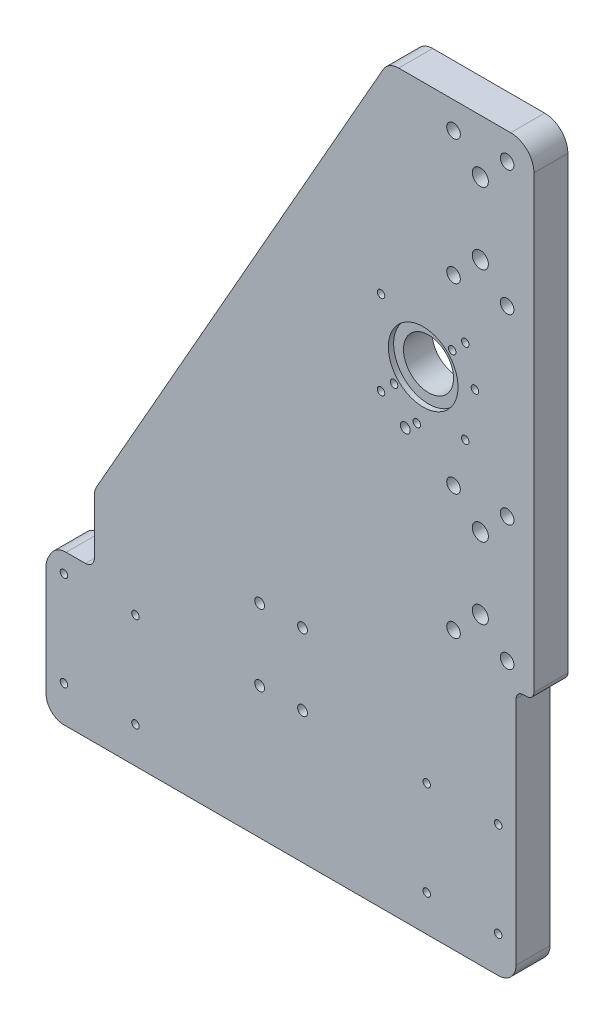
from build123d import *

# Parameters (mm, degrees)
SKETCH2_W               = 270.829085825
SKETCH2_H               = 402
BOSS_EXTRUDE1_DEPTH     = 19
SKETCH3_W               = 7.829085824
SKETCH3_H               = 419.560715459
CUT_EXTRUDE1_DEPTH      = 20
CUT_EXTRUDE2_DEPTH      = 20
FILLET1_R               = 10
TAP_DRILL_FOR_M5_TAP1_D = 4.2
FILLET2_R               = 3
M7_CLEARANCE_HOLE1_D    = 7.6
SKETCH11_R              = 19.5
CUT_EXTRUDE4_DEPTH      = 32.266788686
CUT_EXTRUDE5_DEPTH      = 20
FILLET3_R               = 10
FILLET4_R               = 5
TAP_DRILL_FOR_M5_TAP2_D = 4.2
BOSS_EXTRUDE2_DEPTH     = 19
SKETCH16_R              = 19.5
SKETCH16_R_2            = 14
BOSS_EXTRUDE3_DEPTH     = 16
M5_CLEARANCE_HOLE4_D    = 5.5
M5_CLEARANCE_HOLE5_D    = 5.5
M8_CLEARANCE_HOLE1_D    = 9
TAP_DRILL_FOR_M5_TAP3_D = 4.2
CUT_EXTRUDE6_DEPTH      = 4


with BuildPart() as part:
    # Sketch2 → Boss-Extrude1 (new body)
    with BuildSketch(Plane.XY.offset(94)):
        with Locations((2322.392578952, 658.909518743)):
            Rectangle(SKETCH2_W, SKETCH2_H)
    extrude(amount=BOSS_EXTRUDE1_DEPTH)

    # Sketch3 → Cut-Extrude1 (cut)
    with BuildSketch(Plane.XY.offset(113)):
        with Locations((2190.892578951, 654.789569031)):
            Rectangle(SKETCH3_W, SKETCH3_H)
    extrude(amount=-CUT_EXTRUDE1_DEPTH, mode=Mode.SUBTRACT)

    # Sketch4 → Cut-Extrude2 (cut)
    with BuildSketch(Plane.XY.offset(113)):
        Polygon((2194.807121863, 532.656963015), (2380.609228318, 859.909518743), (2194.807121863, 859.909518743), align=None)
    extrude(amount=-CUT_EXTRUDE2_DEPTH, mode=Mode.SUBTRACT)

    # Fillet1
    fillet1_edges = [part.edges().sort_by_distance(p)[0] for p in [
        (2194.807121863, 457.909518743, 103.5),
        (2194.807121863, 532.656963015, 103.5),
        (2380.609228318, 859.909518743, 103.5),
        (2457.807121864, 457.909518743, 103.5),
    ]]
    fillet(fillet1_edges, radius=FILLET1_R)

    # Tap Drill for M5 Tap1 (through all)
    with Locations(Plane.XY.offset(113)):
        with Locations((2338.307121864, 531.660659234), (2314.307121864, 531.660659234), (2314.307121864, 571.660659234), (2338.307121864, 571.660659234), (2447.807121864, 531.160659234), (2447.807121864, 478.160659234), (2407.807121864, 478.160659234), (2407.807121864, 531.160659234), (2244.807121863, 531.160659234), (2244.807121863, 478.160659234), (2204.807121863, 478.160659234), (2204.807121863, 531.160659234)):
            Hole(TAP_DRILL_FOR_M5_TAP1_D / 2)

    # Fillet2
    fillet2_edges = [part.edges().sort_by_distance(p)[0] for p in [
        (2457.807121864, 859.909518743, 103.5),
    ]]
    fillet(fillet2_edges, radius=FILLET2_R)

    # M7 Clearance Hole1 (through all)
    with Locations(Plane.XY.offset(113)):
        with Locations((2422.807121864, 612.909518743), (2437.807121864, 627.909518743), (2452.807121864, 612.909518743), (2452.807121864, 682.909518743), (2437.807121864, 667.909518743), (2422.807121864, 682.909518743), (2452.807121864, 784.909518743), (2422.807121864, 854.909518743), (2452.807121864, 854.909518743), (2422.807121864, 784.909518743), (2437.807121864, 799.909518743), (2437.807121864, 839.909518743)):
            Hole(M7_CLEARANCE_HOLE1_D / 2)

    # Sketch11 → Cut-Extrude4 (cut)
    with BuildSketch(Plane.XY.offset(113)):
        with Locations((2405.807121866, 731.909518744)):
            Circle(SKETCH11_R)
    extrude(amount=-CUT_EXTRUDE4_DEPTH, mode=Mode.SUBTRACT)

    # Sketch12 → Cut-Extrude5 (cut)
    with BuildSketch(Plane.XY.offset(113)):
        Polygon((2221.807121863, 542.160659234), (2189.780449764, 542.160659234), (2221.807121863, 583.425794439), align=None)
    extrude(amount=-CUT_EXTRUDE5_DEPTH, mode=Mode.SUBTRACT)

    # Fillet3
    fillet3_edges = [part.edges().sort_by_distance(p)[0] for p in [
        (2200.202975144, 542.160659234, 103.5),
        (2221.807121863, 580.211962112, 103.5),
    ]]
    fillet(fillet3_edges, radius=FILLET3_R)

    # Fillet4
    fillet4_edges = [part.edges().sort_by_distance(p)[0] for p in [
        (2221.807121863, 542.160659234, 103.5),
    ]]
    fillet(fillet4_edges, radius=FILLET4_R)

    # Tap Drill for M5 Tap2 (through all)
    with Locations(Plane(origin=(0, 0, 94), x_dir=(-1, 0, 0), z_dir=(0, 0, -1))):
        with Locations((-2429.377121866, 755.479518745), (-2382.237121866, 755.479518745), (-2429.377121866, 708.339518745), (-2382.237121866, 708.339518745)):
            Hole(TAP_DRILL_FOR_M5_TAP2_D / 2)

    # Sketch15 → Boss-Extrude2 (add)
    with BuildSketch(Plane.XY.offset(113)):
        with BuildLine():
            Line((2457.807121864, 856.909518743), (2457.807121864, 597.10478226))
            ThreePointArc((2457.807121864, 597.10478226), (2458.978694739, 599.933209385), (2461.807121864, 601.10478226))
            Line((2461.807121864, 601.10478226), (2463.807121864, 601.10478226))
            ThreePointArc((2463.807121864, 601.10478226), (2466.635548988, 602.276355135), (2467.807121864, 605.10478226))
            Line((2467.807121864, 605.10478226), (2467.807121864, 856.909518743))
            ThreePointArc((2467.807121864, 856.909518743), (2463.999510019, 866.101906899), (2454.807121864, 869.909518743))
            Line((2454.807121864, 869.909518743), (2392.108600325, 869.909518743))
            ThreePointArc((2392.108600325, 869.909518743), (2387.077370287, 868.551666874), (2383.412473272, 864.846863605))
            Line((2383.412473272, 864.846863605), (2377.734836743, 854.846863605))
            ThreePointArc((2377.734836743, 854.846863605), (2381.399733758, 858.551666874), (2386.430963796, 859.909518743))
            Line((2386.430963796, 859.909518743), (2454.807121864, 859.909518743))
            ThreePointArc((2454.807121864, 859.909518743), (2456.928442207, 859.030839087), (2457.807121864, 856.909518743))
        make_face()
    extrude(amount=-BOSS_EXTRUDE2_DEPTH)

    # Sketch16 → Boss-Extrude3 (add)
    with BuildSketch(Plane(origin=(0, 0, 94), x_dir=(-1, 0, 0), z_dir=(0, 0, -1))):
        with Locations((-2405.807121866, 731.909518744)):
            Circle(SKETCH16_R)
        with Locations((-2405.807121866, 731.909518744)):
            Circle(SKETCH16_R_2, mode=Mode.SUBTRACT)
    extrude(amount=-BOSS_EXTRUDE3_DEPTH)

    # M5 Clearance Hole4 (through all)
    with Locations(Plane(origin=(0, 0, 94), x_dir=(-1, 0, 0), z_dir=(0, 0, -1))):
        with Locations((-2395.807121866, 697.409518744)):
            Hole(M5_CLEARANCE_HOLE4_D / 2)

    # M5 Clearance Hole5 (through all)
    with Locations(Plane(origin=(0, 0, 94), x_dir=(-1, 0, 0), z_dir=(0, 0, -1))):
        with Locations((-2338.307121864, 531.660659234), (-2314.307121864, 531.660659234), (-2314.307121864, 571.660659234), (-2338.307121864, 571.660659234)):
            Hole(M5_CLEARANCE_HOLE5_D / 2)

    # M8 Clearance Hole1 (through all)
    with Locations(Plane(origin=(0, 0, 94), x_dir=(-1, 0, 0), z_dir=(0, 0, -1))):
        with Locations((-2437.807121864, 627.909518743), (-2437.807121864, 667.909518743), (-2437.807121864, 799.909518743), (-2437.807121864, 839.909518743)):
            Hole(M8_CLEARANCE_HOLE1_D / 2)

    # Tap Drill for M5 Tap3 (through all)
    with Locations(Plane(origin=(0, 0, 94), x_dir=(-1, 0, 0), z_dir=(0, 0, -1))):
        with Locations((-2422.070577833, 748.172974712), (-2434.798499894, 735.445052651), (-2402.27158796, 702.918140716), (-2389.543665898, 715.646062777)):
            Hole(TAP_DRILL_FOR_M5_TAP3_D / 2)

    # Sketch25 → Cut-Extrude6 (cut)
    with BuildSketch(Plane(origin=(0, 0, 94), x_dir=(-1, 0, 0), z_dir=(0, 0, -1))):
        Polygon((-2430.208565254, 735.445052651), (-2432.503532574, 739.420052651), (-2437.093467214, 739.420052651), (-2439.388434534, 735.445052651), (-2437.093467214, 731.470052651), (-2432.503532574, 731.470052651), align=None)
        Polygon((-2426.660512473, 748.172974712), (-2424.365545153, 744.197974712), (-2419.775610513, 744.197974712), (-2417.480643193, 748.172974712), (-2419.775610513, 752.147974712), (-2424.365545153, 752.147974712), align=None)
        Polygon((-2402.27158796, 707.508075356), (-2406.24658796, 705.213108036), (-2406.24658796, 700.623173396), (-2402.27158796, 698.328206076), (-2398.29658796, 700.623173396), (-2398.29658796, 705.213108036), align=None)
        Polygon((-2389.543665898, 720.235997418), (-2393.518665898, 717.941030098), (-2393.518665898, 713.351095457), (-2389.543665898, 711.056128137), (-2385.568665898, 713.351095457), (-2385.568665898, 717.941030098), align=None)
    extrude(amount=-CUT_EXTRUDE6_DEPTH, mode=Mode.SUBTRACT)


solid = part.part
